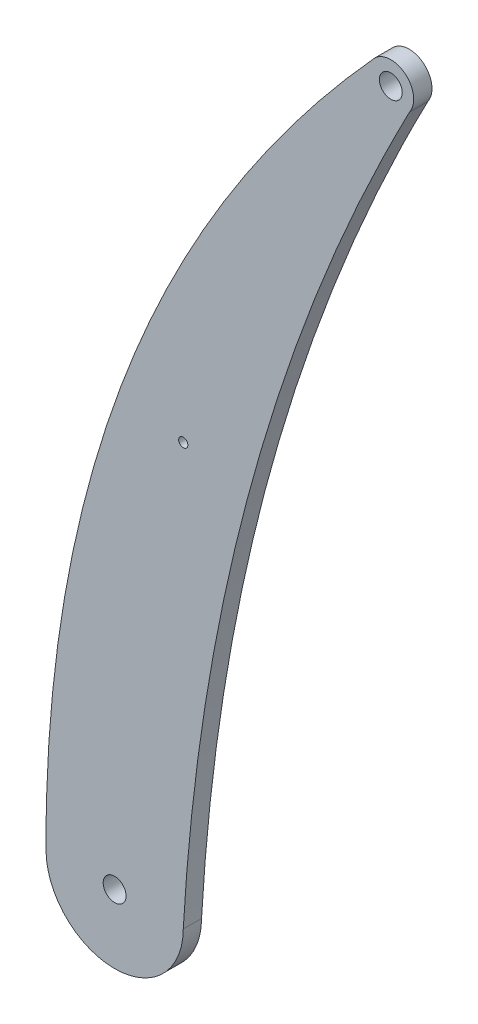
from build123d import *

# Parameters (mm, degrees)
SKETCH1_R           = 2.5
SKETCH1_R_2         = 1
BOSS_EXTRUDE1_DEPTH = 4


with BuildPart() as part:
    # Sketch1 → Boss-Extrude1 (new body)
    with BuildSketch(Plane.XY):
        with BuildLine():
            ThreePointArc((15.254156194, 5.023677433), (14.359298867, 11.726874121), (7.604193017, 11.407248683))
            add(Edge.make_bspline(
                [(7.604193017, 11.407248683), (-64.624332124, -68.096129446), (-64.220975839, -174.388465928)],
                knots=[0, 0, 0, 1, 1, 1], degree=2))
            ThreePointArc((-64.220975839, -174.388465928), (-49.220975839, -189.388465928), (-34.220975839, -174.388465928))
            add(Edge.make_bspline(
                [(15.254156194, 5.023677433), (-28.824565765, -79.354910708), (-34.220975839, -174.388465928)],
                knots=[0, 0, 0, 1, 1, 1], degree=2))
        make_face()
        with Locations((11.155830006, 7.88789154)):
            Circle(SKETCH1_R, mode=Mode.SUBTRACT)
        with Locations((-34.220975839, -82.261849143)):
            Circle(SKETCH1_R_2, mode=Mode.SUBTRACT)
        with Locations((-49.220975839, -174.388465928)):
            Circle(SKETCH1_R, mode=Mode.SUBTRACT)
    extrude(amount=BOSS_EXTRUDE1_DEPTH)


solid = part.part
